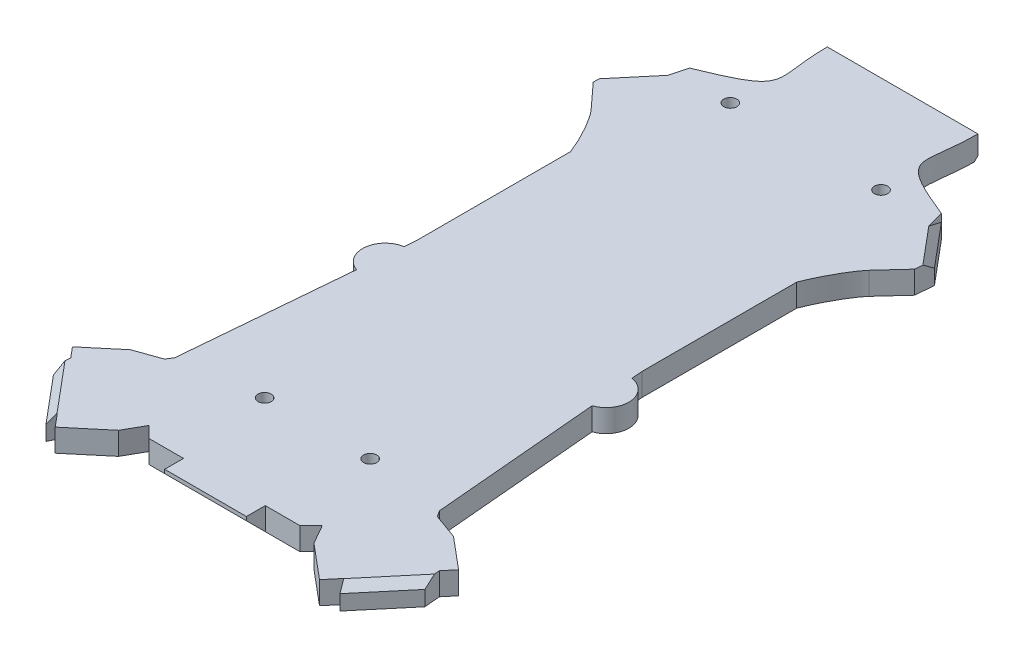
from build123d import *
from OCP.BRepFilletAPI import BRepFilletAPI_MakeChamfer

# Parameters (mm, degrees)
SKETCH1_W             = 60
SKETCH1_H             = 180
BOSS_EXTRUDE1_DEPTH   = 6
CHAMFER2_SIZE         = 10
BOSS_EXTRUDE3_DEPTH   = 6
BOSS_EXTRUDE4_DEPTH   = 6
CHAMFER14_SIZE        = 2
CHAMFER16_SIZE        = 7
CHAMFER16_SIZE2       = 56.79198309
CHAMFER17_SIZE        = 2
SKETCH59_W            = 21.7
SKETCH59_H            = 5
BOSS_EXTRUDE5_DEPTH   = 6
CHAMFER19_SIZE        = 5
CUT_EXTRUDE28_DEPTH   = 112.04216162
CHAMFER20_SIZE        = 3
CHAMFER20_SIZE2       = 3.484649721
CUT_EXTRUDE29_DEPTH   = 111.166083192
CHAMFER24_SIZE        = 1
CUT_EXTRUDE31_DEPTH   = 111.166083332
SKETCH66_R            = 6
BOSS_EXTRUDE6_DEPTH   = 6
BOSS_EXTRUDE7_DEPTH   = 6
BOSS_EXTRUDE8_DEPTH   = 6
BOSS_EXTRUDE9_DEPTH   = 6
F_3_0MM_DOWEL_HOLE3_D = 3.5


with BuildPart() as part:
    # Sketch1 → Boss-Extrude1 (new body)
    with BuildSketch(Plane(origin=(0, 0, 0), x_dir=(1, 0, 0), z_dir=(0, 1, 0))):
        Rectangle(SKETCH1_W, SKETCH1_H)
    extrude(amount=BOSS_EXTRUDE1_DEPTH)

    # Chamfer2
    chamfer2_edges = [part.edges().sort_by_distance(p)[0] for p in [
        (-30, 3, -90),
        (30, 3, -90),
        (30, 3, 90),
        (-30, 3, 90),
    ]]
    chamfer(chamfer2_edges, length=CHAMFER2_SIZE)

    # Sketch52 → Boss-Extrude3 (add, through all)
    with BuildSketch(Plane(origin=(0, 6, 0), x_dir=(1, 0, 0), z_dir=(0, 1, 0))):
        Polygon((45, 53.067924807), (36.85, 44.173760523), (30, 25.3535402), (30, 79.656998575), (33.429823026, 66.856724783), align=None)
        Polygon((-33.429823026, 66.856724783), (-45, 53.067924807), (-36.85, 44.173760523), (-30, 25.3535402), (-30, 79.656998575), align=None)
    extrude(amount=-BOSS_EXTRUDE3_DEPTH)

    # Sketch53 → Boss-Extrude4 (add, through all)
    with BuildSketch(Plane(origin=(0, 6, 0), x_dir=(1, 0, 0), z_dir=(0, 1, 0))):
        Polygon((30, -65.989627063), (30, -80), (39, -98.344262241), (51.212964584, -83.789417822), align=None)
        Polygon((-51.212964584, -83.789417822), (-30, -65.989627063), (-30, -80), (-39, -98.344262241), align=None)
    extrude(amount=-BOSS_EXTRUDE4_DEPTH)

    # Chamfer14
    chamfer14_edges = [part.edges().sort_by_distance(p)[0] for p in [
        (-45.106482292, 6, 91.066840031),
        (45.106482292, 6, 91.066840031),
    ]]
    chamfer(chamfer14_edges, length=CHAMFER14_SIZE)

    # Chamfer16: one chamfer whose edges measure the first distance from different faces: ONE call of the kernel's chamfer builder (chamfer() names one face for all edges)
    chamfer16_edges_1 = [part.edges().sort_by_distance(p)[0] for p in [
        (-30, 3, 65.989627063),
    ]]
    chamfer16_side_1 = [part.faces().sort_by_distance(p)[0] for p in [
        (-40.483474971, 2.971570606, 74.786307045),
    ]]
    chamfer16_edges_2 = [part.edges().sort_by_distance(p)[0] for p in [
        (30, 3, 65.989627063),
    ]]
    chamfer16_side_2 = [part.faces().sort_by_distance(p)[0] for p in [
        (40.483474971, 2.971570606, 74.786307045),
    ]]
    chamfer16 = BRepFilletAPI_MakeChamfer(part.part.solid().wrapped)
    for e in chamfer16_edges_1:
        chamfer16.Add(CHAMFER16_SIZE, CHAMFER16_SIZE2, e.wrapped, chamfer16_side_1[0].wrapped)  # the first distance lies on this face
    for e in chamfer16_edges_2:
        chamfer16.Add(CHAMFER16_SIZE, CHAMFER16_SIZE2, e.wrapped, chamfer16_side_2[0].wrapped)  # the first distance lies on this face
    add(Compound.cast(chamfer16.Shape()), mode=Mode.REPLACE)

    # Chamfer17
    chamfer17_edges = [part.edges().sort_by_distance(p)[0] for p in [
        (39.214911513, 6, -59.962324795),
        (-39.214911513, 6, -59.962324795),
    ]]
    chamfer(chamfer17_edges, length=CHAMFER17_SIZE)

    # Sketch59 → Boss-Extrude5 (add, through all)
    with BuildSketch(Plane(origin=(0, 6, 0), x_dir=(1, 0, 0), z_dir=(0, 1, 0))):
        with Locations((0, -92.5)):
            Rectangle(SKETCH59_W, SKETCH59_H)
    extrude(amount=-BOSS_EXTRUDE5_DEPTH)

    # Chamfer19
    chamfer19_edges = [part.edges().sort_by_distance(p)[0] for p in [
        (0, 0, 95),
    ]]
    chamfer(chamfer19_edges, length=CHAMFER19_SIZE)

    # Sketch61 → Cut-Extrude28 (cut, through all)
    with BuildSketch(Plane.XZ):
        Polygon((30, -79.656998575), (20, -90), (30, -80), align=None)
        Polygon((-30, -80), (-30, -79.656998575), (-20, -90), align=None)
    extrude(amount=-CUT_EXTRUDE28_DEPTH, mode=Mode.SUBTRACT)

    # Chamfer20: one chamfer whose edges measure the first distance from different faces: ONE call of the kernel's chamfer builder (chamfer() names one face for all edges)
    chamfer20_edges_1 = [part.edges().sort_by_distance(p)[0] for p in [
        (-45, 2, -53.067924807),
    ]]
    chamfer20_side_1 = [part.faces().sort_by_distance(p)[0] for p in [
        (-40.821197815, 2.933105821, -48.507562458),
    ]]
    chamfer20_edges_2 = [part.edges().sort_by_distance(p)[0] for p in [
        (45, 2, -53.067924807),
    ]]
    chamfer20_side_2 = [part.faces().sort_by_distance(p)[0] for p in [
        (39.214911513, 2, -59.962324795),
    ]]
    chamfer20_edges_3 = [part.edges().sort_by_distance(p)[0] for p in [
        (-51.212964584, 2, 83.789417822),
        (51.212964584, 2, 83.789417822),
    ]]
    chamfer20 = BRepFilletAPI_MakeChamfer(part.part.solid().wrapped)
    for e in chamfer20_edges_1:
        chamfer20.Add(CHAMFER20_SIZE, CHAMFER20_SIZE2, e.wrapped, chamfer20_side_1[0].wrapped)  # the first distance lies on this face
    for e in chamfer20_edges_2:
        chamfer20.Add(CHAMFER20_SIZE, CHAMFER20_SIZE2, e.wrapped, chamfer20_side_2[0].wrapped)  # the first distance lies on this face
    for e in chamfer20_edges_3:
        chamfer20.Add(CHAMFER20_SIZE, e.wrapped)
    add(Compound.cast(chamfer20.Shape()), mode=Mode.REPLACE)

    # Sketch62 → Cut-Extrude29 (cut, through all)
    with BuildSketch(Plane(origin=(0, 6, 0), x_dir=(1, 0, 0), z_dir=(0, 1, 0))):
        with BuildLine():
            Line((20, 90), (30, 79.656998575))
            Line((30, 79.656998575), (33.429823026, 66.856724783))
            add(Edge.make_bspline(
                [(33.429823026, 66.856724783), (13.849706238, 74.804707739), (20, 74.573823319), (20, 90)],
                knots=[0, 0, 0, 0, 1, 1, 1, 1], degree=3))
        make_face()
        with BuildLine():
            Line((-30, 79.656998575), (-33.429823026, 66.856724783))
            add(Edge.make_bspline(
                [(-33.429823026, 66.856724783), (-13.849706238, 74.804707739), (-20, 74.573823319), (-20, 90)],
                knots=[0, 0, 0, 0, 1, 1, 1, 1], degree=3))
            Line((-20, 90), (-30, 79.656998575))
        make_face()
    extrude(amount=-CUT_EXTRUDE29_DEPTH, mode=Mode.SUBTRACT)

    # Chamfer24
    chamfer24_edges = [part.edges().sort_by_distance(p)[0] for p in [
        (0, 0, -90),
    ]]
    chamfer(chamfer24_edges, length=CHAMFER24_SIZE)

    # Sketch64 → Cut-Extrude31 (cut, through all)
    with BuildSketch(Plane(origin=(0, 6, 0), x_dir=(1, 0, 0), z_dir=(0, 1, 0))):
        with BuildLine():
            Line((36.85, 44.173760523), (25, 5.3535402))
            add(Edge.make_bspline(
                [(25, 5.3535402), (25, 11.888533403), (26.675205792, 28.424746849), (35.495075594, 42.695120001), (36.85, 44.173760523)],
                knots=[0, 0, 0, 0, 0.750989917, 1, 1, 1, 1], degree=3))
        make_face()
        with BuildLine():
            Line((-36.85, 44.173760523), (-25, 5.3535402))
            add(Edge.make_bspline(
                [(-25, 5.3535402), (-25, 11.888533403), (-26.675205792, 28.424746849), (-35.495075594, 42.695120001), (-36.85, 44.173760523)],
                knots=[0, 0, 0, 0, 0.750989917, 1, 1, 1, 1], degree=3))
        make_face()
    extrude(amount=-CUT_EXTRUDE31_DEPTH, mode=Mode.SUBTRACT)

    # Sketch66 → Boss-Extrude6 (add)
    with BuildSketch(Plane(origin=(0, 6, 0), x_dir=(1, 0, 0), z_dir=(0, 1, 0))):
        with Locations((29.320888862, -18)):
            Circle(SKETCH66_R)
        with BuildLine():
            ThreePointArc((25, -13.837078017), (26.973287097, -12.478336668), (29.320888862, -12))
            Line((29.320888862, -12), (25, -12))
            Line((25, -12), (25, -13.837078017))
        make_face()
        with BuildLine():
            Line((25, -24), (29.320888862, -24))
            ThreePointArc((29.320888862, -24), (26.973287097, -23.521663332), (25, -22.162921983))
            Line((25, -22.162921983), (25, -24))
        make_face()
        with Locations((-29.320888862, -18)):
            Circle(SKETCH66_R)
        with BuildLine():
            Line((-25, -12), (-29.320888862, -12))
            ThreePointArc((-29.320888862, -12), (-26.973287097, -12.478336668), (-25, -13.837078017))
            Line((-25, -13.837078017), (-25, -12))
        make_face()
        with BuildLine():
            ThreePointArc((-25, -22.162921983), (-26.973287097, -23.521663332), (-29.320888862, -24))
            Line((-29.320888862, -24), (-25, -24))
            Line((-25, -24), (-25, -22.162921983))
        make_face()
    extrude(amount=-BOSS_EXTRUDE6_DEPTH)

    # Sketch67 → Boss-Extrude7 (add)
    with BuildSketch(Plane.XZ):
        with BuildLine():
            Line((30, -21.733379998), (30, -31.878802778))
            add(Edge.make_bspline(
                [(30, -31.878802778), (26.006043433, -21.746256389), (25, -11.197434735), (25, -5.3535402)],
                knots=[0.328429926, 0.328429926, 0.328429926, 0.328429926, 1, 1, 1, 1], degree=3))
            Line((25, -5.3535402), (30, -21.733379998))
        make_face()
        with BuildLine():
            Line((-30, -21.733379998), (-30, -31.878802778))
            add(Edge.make_bspline(
                [(-25, -5.3535402), (-25, -11.197434735), (-26.006043433, -21.746256389), (-30, -31.878802778)],
                knots=[0, 0, 0, 0, 0.671570074, 0.671570074, 0.671570074, 0.671570074], degree=3))
            Line((-25, -5.3535402), (-30, -21.733379998))
        make_face()
    extrude(amount=-BOSS_EXTRUDE7_DEPTH)

    # Sketch70 → Boss-Extrude8 (add)
    with BuildSketch(Plane(origin=(0, 6, 0), x_dir=(1, 0, 0), z_dir=(0, 1, 0))):
        Polygon((-35.152040134, -68.085732174), (-36.207663424, -69.695157895), (-42.867802278, -72.070563218), (-51.23722065, -79.093339087), (-48.914831255, -81.861054993), (-35.362311102, -70.489140331), align=None)
        Polygon((-37.956015914, -96.380824876), (-29.919310924, -80), (-22.966994839, -86.952316085), (-25.929369827, -92.160839448), (-35.064832642, -99.826402927), align=None)
        Polygon((35.362311102, -70.489140331), (48.914831255, -81.861054993), (51.23722065, -79.093339087), (42.867802278, -72.070563218), (36.207663424, -69.695157895), (35.152040134, -68.085732174), align=None)
        Polygon((37.956015914, -96.380824876), (29.919310924, -80), (22.966994839, -86.952316085), (25.929369827, -92.160839448), (35.064832642, -99.826402927), align=None)
    extrude(amount=-BOSS_EXTRUDE8_DEPTH)

    # Sketch71 → Boss-Extrude9 (add)
    with BuildSketch(Plane(origin=(0, 6, 0), x_dir=(1, 0, 0), z_dir=(0, 1, 0))):
        Polygon((-38.03670499, -96.380824876), (-37.956015914, -96.380824876), (-29.945868659, -80.054131341), (-30, -80), align=None)
        Polygon((29.945868659, -80.054131341), (37.956015914, -96.380824876), (38.03670499, -96.380824876), (30, -80), align=None)
    extrude(amount=-BOSS_EXTRUDE9_DEPTH)

    # Ø3.0mm Dowel Hole3 (through all)
    with Locations(Plane(origin=(0, 6, 0), x_dir=(1, 0, 0), z_dir=(0, 1, 0))):
        with Locations((20, 64.260302334), (-20, 64.260302334), (-14, -65.321451812), (14, -65.321451812)):
            Hole(F_3_0MM_DOWEL_HOLE3_D / 2)


solid = part.part
